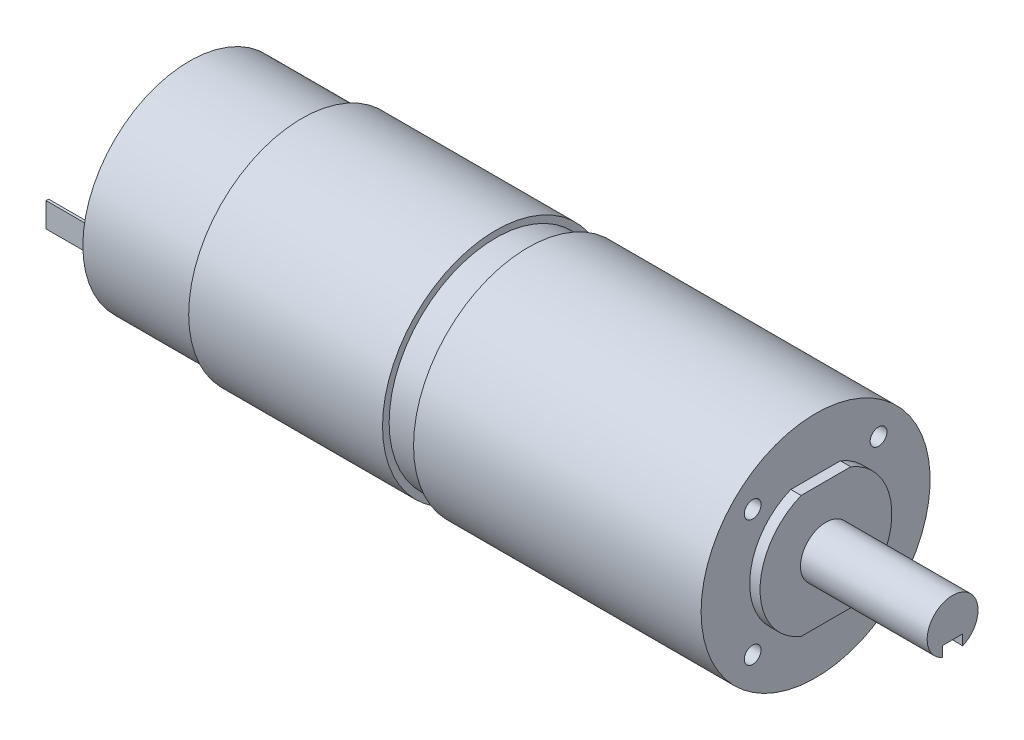
from build123d import *

# Parameters (mm, degrees)
CUT_EXTRUDE1_DEPTH              = 18.0086
CUT_EXTRUDE2_DEPTH              = 2.032
TAP_DRILL_FOR_M4X0_7_TAP2_D     = 3.3
TAP_DRILL_FOR_M4X0_7_TAP2_DEPTH = 12.7
SKETCH8_W                       = 8.89
SKETCH8_H                       = 4.826
BOSS_EXTRUDE1_DEPTH             = 0.254


with BuildPart() as part:
    # Sketch1 → Revolve1 (revolve)
    with BuildSketch(Plane.XY):
        Polygon((0, 0), (0, 3.81), (5.08, 3.81), (5.08, 11.43), (9.017, 11.43), (9.017, 20.955), (31.115, 20.955), (31.115, 22.2504), (69.215, 22.2504), (69.215, 20.955), (75.565, 20.955), (75.565, 22.5044), (132.08, 22.5044), (132.08, 12.954), (134.112, 12.954), (134.112, 4.99999), (159.004, 4.99999), (159.004, 0), align=None)
    revolve(axis=Axis((0, 0, 0), (1, 0, 0)))

    # Sketch2 → Cut-Extrude1 (cut)
    with BuildSketch(Plane(origin=(159.004, 0, 0), x_dir=(0, 0, -1), z_dir=(1, 0, 0))):
        with BuildLine():
            Line((-1.9939, -4.585222218), (-1.9939, -2.553222218))
            Line((-1.9939, -2.553222218), (1.9939, -2.553222218))
            Line((1.9939, -2.553222218), (1.9939, -4.585222218))
            ThreePointArc((1.9939, -4.585222218), (0, -4.99999), (-1.9939, -4.585222218))
        make_face()
    extrude(amount=-CUT_EXTRUDE1_DEPTH, mode=Mode.SUBTRACT)

    # Sketch3 → Cut-Extrude2 (cut)
    with BuildSketch(Plane(origin=(134.112, 0, 0), x_dir=(0, 0, -1), z_dir=(1, 0, 0))):
        with BuildLine():
            Line((-4.875460363, 12.0015), (4.875460363, 12.0015))
            ThreePointArc((4.875460363, 12.0015), (0, 12.954), (-4.875460363, 12.0015))
        make_face()
        with BuildLine():
            Line((-4.875460363, -12.0015), (4.875460363, -12.0015))
            ThreePointArc((4.875460363, -12.0015), (0, -12.954), (-4.875460363, -12.0015))
        make_face()
    extrude(amount=-CUT_EXTRUDE2_DEPTH, mode=Mode.SUBTRACT)

    # Tap Drill for M4x0.7 Tap2
    with Locations(Plane(origin=(132.08, 0, 0), x_dir=(0, 0, -1), z_dir=(1, 0, 0))):
        with Locations((-12.374792935, 12.374792935), (12.374792935, -12.374792935), (12.374792935, 12.374792935), (-12.374792935, -12.374792935)):
            Hole(TAP_DRILL_FOR_M4X0_7_TAP2_D / 2, depth=TAP_DRILL_FOR_M4X0_7_TAP2_DEPTH)

    # Sketch8 → Boss-Extrude1 (add, symmetric)
    with BuildSketch(Plane.XY.offset(19.05)):
        with Locations((4.572, 0)):
            Rectangle(SKETCH8_W, SKETCH8_H)
    boss_extrude1 = extrude(amount=BOSS_EXTRUDE1_DEPTH, both=True)

    # Mirror1: Boss-Extrude1 across plane
    add(boss_extrude1.mirror(Plane.XY))


solid = part.part
